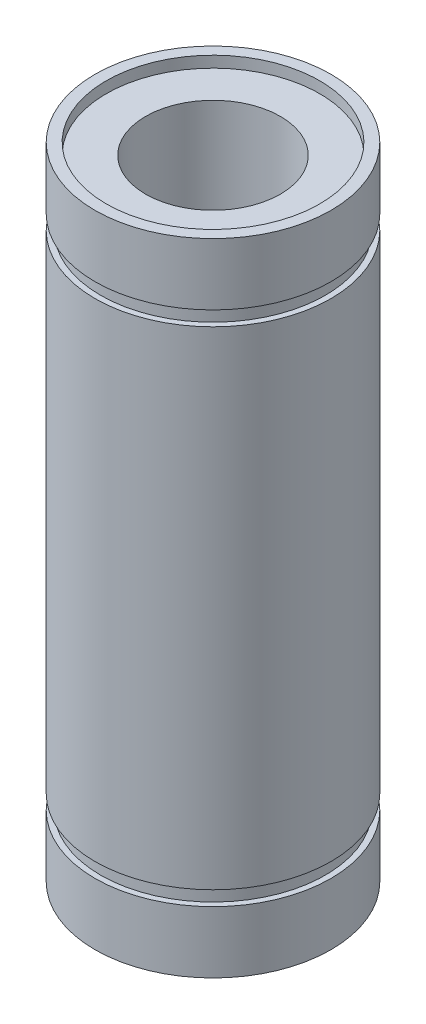
from build123d import *

# Parameters (mm, degrees)
SKETCH1_R         = 10.5
SKETCH1_R_2       = 6
EXTRUDE1_DEPTH    = 57
SKETCH2_R         = 9.5
EXTRUDE2_DEPTH    = 1
SKETCH3_R         = 9.5
EXTRUDE3_DEPTH    = 1
SKETCH4_OUTSIDE_W = 35.854
SKETCH4_OUTSIDE_H = 35.854
SKETCH4_OUTSIDE_R = 10
EXTRUDE4_DEPTH    = 1.3
SKETCH5_OUTSIDE_W = 35.854
SKETCH5_OUTSIDE_H = 35.854
SKETCH5_OUTSIDE_R = 10
EXTRUDE5_DEPTH    = 1.3


with BuildPart() as part:
    # Sketch1 → Extrude1 (new body)
    with BuildSketch(Plane(origin=(0, 0, 0), x_dir=(1, 0, 0), z_dir=(0, 1, 0))):
        Circle(SKETCH1_R)
        Circle(SKETCH1_R_2, mode=Mode.SUBTRACT)
    extrude(amount=EXTRUDE1_DEPTH)

    # Sketch2 → Extrude2 (cut)
    with BuildSketch(Plane(origin=(0, 57, 0), x_dir=(1, 0, 0), z_dir=(0, 1, 0))):
        Circle(SKETCH2_R)
    extrude(amount=-EXTRUDE2_DEPTH, mode=Mode.SUBTRACT)

    # Sketch3 → Extrude3 (cut)
    with BuildSketch(Plane.XZ):
        Circle(SKETCH3_R)
    extrude(amount=-EXTRUDE3_DEPTH, mode=Mode.SUBTRACT)

    # Sketch4 outside → Extrude4 (cut)
    with BuildSketch(Plane(origin=(0, 51.5, 0), x_dir=(1, 0, 0), z_dir=(0, 1, 0))):
        Rectangle(SKETCH4_OUTSIDE_W, SKETCH4_OUTSIDE_H)
        Circle(SKETCH4_OUTSIDE_R, mode=Mode.SUBTRACT)
    extrude(amount=-EXTRUDE4_DEPTH, mode=Mode.SUBTRACT)

    # Sketch5 outside → Extrude5 (cut)
    with BuildSketch(Plane(origin=(0, 5.5, 0), x_dir=(-1, 0, 0), z_dir=(0, -1, 0))):
        Rectangle(SKETCH5_OUTSIDE_W, SKETCH5_OUTSIDE_H)
        Circle(SKETCH5_OUTSIDE_R, mode=Mode.SUBTRACT)
    extrude(amount=-EXTRUDE5_DEPTH, mode=Mode.SUBTRACT)


solid = part.part
